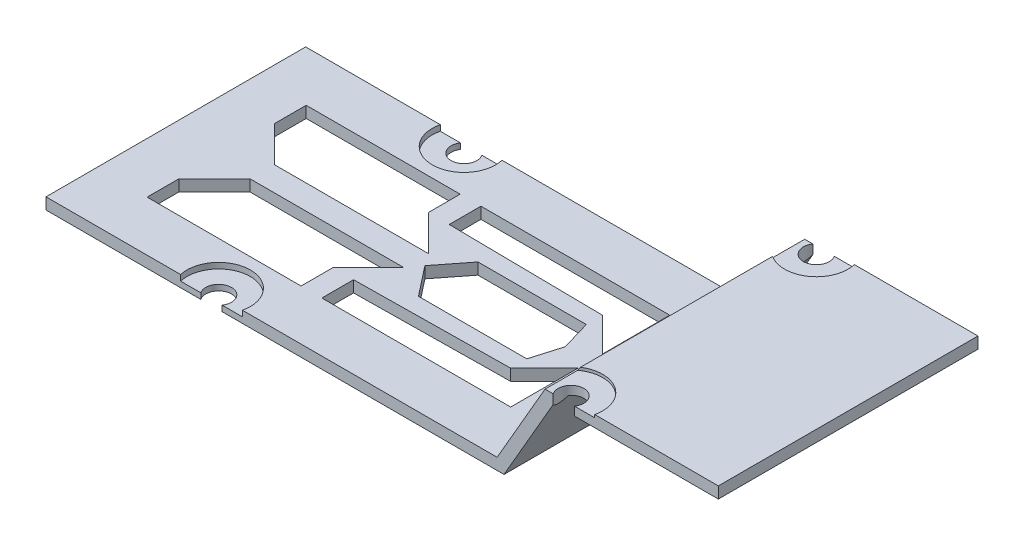
from build123d import *

# Parameters (mm, degrees)
BOSS_EXTRUDE1_DEPTH = 45.38
SKETCH4_R           = 2.25
CUT_EXTRUDE3_DEPTH  = 14.99956
SKETCH5_R           = 5.54
CUT_EXTRUDE4_DEPTH  = 0.5
CUT_EXTRUDE5_DEPTH  = 2
CUT_EXTRUDE6_DEPTH  = 2
SKETCH2_R           = 2.25
CUT_EXTRUDE7_DEPTH  = 2
SKETCH8_R           = 5.54
CUT_EXTRUDE8_DEPTH  = 1


with BuildPart() as part:
    # Sketch1 → Boss-Extrude1 (new body)
    with BuildSketch(Plane.XY):
        Polygon((-73.15434201, 0), (-73.15434201, -2), (6.88994551, -2), (15.54994551, 12.999559994), (44.34565799, 12.999559994), (44.34565799, 14.999559994), (14.34565799, 14.999559994), (5.68565799, 0), align=None)
    extrude(amount=BOSS_EXTRUDE1_DEPTH)

    # Sketch4 → Cut-Extrude3 (cut)
    with BuildSketch(Plane(origin=(0, 14.999559994, 0), x_dir=(1, 0, 0), z_dir=(0, 1, 0))):
        with Locations((17.34565799, -44.13)):
            Circle(SKETCH4_R)
    cut_extrude3 = extrude(amount=-CUT_EXTRUDE3_DEPTH, mode=Mode.SUBTRACT)

    # Sketch5 → Cut-Extrude4 (cut)
    with BuildSketch(Plane(origin=(0, 14.999559994, 0), x_dir=(1, 0, 0), z_dir=(0, 1, 0))):
        with Locations((17.34565799, -44.13)):
            Circle(SKETCH5_R)
    cut_extrude4 = extrude(amount=-CUT_EXTRUDE4_DEPTH, mode=Mode.SUBTRACT)

    # Sketch6 → Cut-Extrude5 (cut)
    with BuildSketch(Plane(origin=(0, 0, 0), x_dir=(1, 0, 0), z_dir=(0, 1, 0))):
        Polygon((-0.73434201, -36.59), (-0.73434201, -24.824385528), (-6.617149247, -30.707192764), (-33.73434201, -31.053746412), (-33.73434201, -36.59), align=None)
        Polygon((-37.368890626, -36.59), (-37.368890626, -31.053746412), (-31.139529741, -24.824385528), (-58.04173908, -24.824385528), (-64.271099965, -31.053746412), (-64.271099965, -36.59), align=None)
    cut_extrude5 = extrude(amount=-CUT_EXTRUDE5_DEPTH, mode=Mode.SUBTRACT)

    # Sketch7 → Cut-Extrude6 (cut)
    with BuildSketch(Plane(origin=(0, 0, 0), x_dir=(1, 0, 0), z_dir=(0, 1, 0))):
        Polygon((-5.095840943, -22.69), (-6.617149247, -27.890480059), (-25.551142536, -27.890480059), (-29.626528294, -22.69), align=None)
    cut_extrude6 = extrude(amount=-CUT_EXTRUDE6_DEPTH, mode=Mode.SUBTRACT)

    # Sketch2 → Cut-Extrude7 (cut)
    with BuildSketch(Plane(origin=(0, 0, 0), x_dir=(1, 0, 0), z_dir=(0, 1, 0))):
        with Locations((-44.23434201, -44.13)):
            Circle(SKETCH2_R)
    cut_extrude7 = extrude(amount=-CUT_EXTRUDE7_DEPTH, mode=Mode.SUBTRACT)

    # Sketch8 → Cut-Extrude8 (cut)
    with BuildSketch(Plane(origin=(0, 0, 0), x_dir=(1, 0, 0), z_dir=(0, 1, 0))):
        with Locations((-44.23434201, -44.13)):
            Circle(SKETCH8_R)
    cut_extrude8 = extrude(amount=-CUT_EXTRUDE8_DEPTH, mode=Mode.SUBTRACT)

    # Mirror1: Cut-Extrude3, Cut-Extrude4, Cut-Extrude5, Cut-Extrude6, Cut-Extrude7, Cut-Extrude8 across plane
    add(cut_extrude3.mirror(Plane(origin=(0, 0, 22.69), x_dir=(1, 0, 0), z_dir=(0, 0, -1))), mode=Mode.SUBTRACT)
    add(cut_extrude4.mirror(Plane(origin=(0, 0, 22.69), x_dir=(1, 0, 0), z_dir=(0, 0, -1))), mode=Mode.SUBTRACT)
    add(cut_extrude5.mirror(Plane(origin=(0, 0, 22.69), x_dir=(1, 0, 0), z_dir=(0, 0, -1))), mode=Mode.SUBTRACT)
    add(cut_extrude6.mirror(Plane(origin=(0, 0, 22.69), x_dir=(1, 0, 0), z_dir=(0, 0, -1))), mode=Mode.SUBTRACT)
    add(cut_extrude7.mirror(Plane(origin=(0, 0, 22.69), x_dir=(1, 0, 0), z_dir=(0, 0, -1))), mode=Mode.SUBTRACT)
    add(cut_extrude8.mirror(Plane(origin=(0, 0, 22.69), x_dir=(1, 0, 0), z_dir=(0, 0, -1))), mode=Mode.SUBTRACT)


solid = part.part
